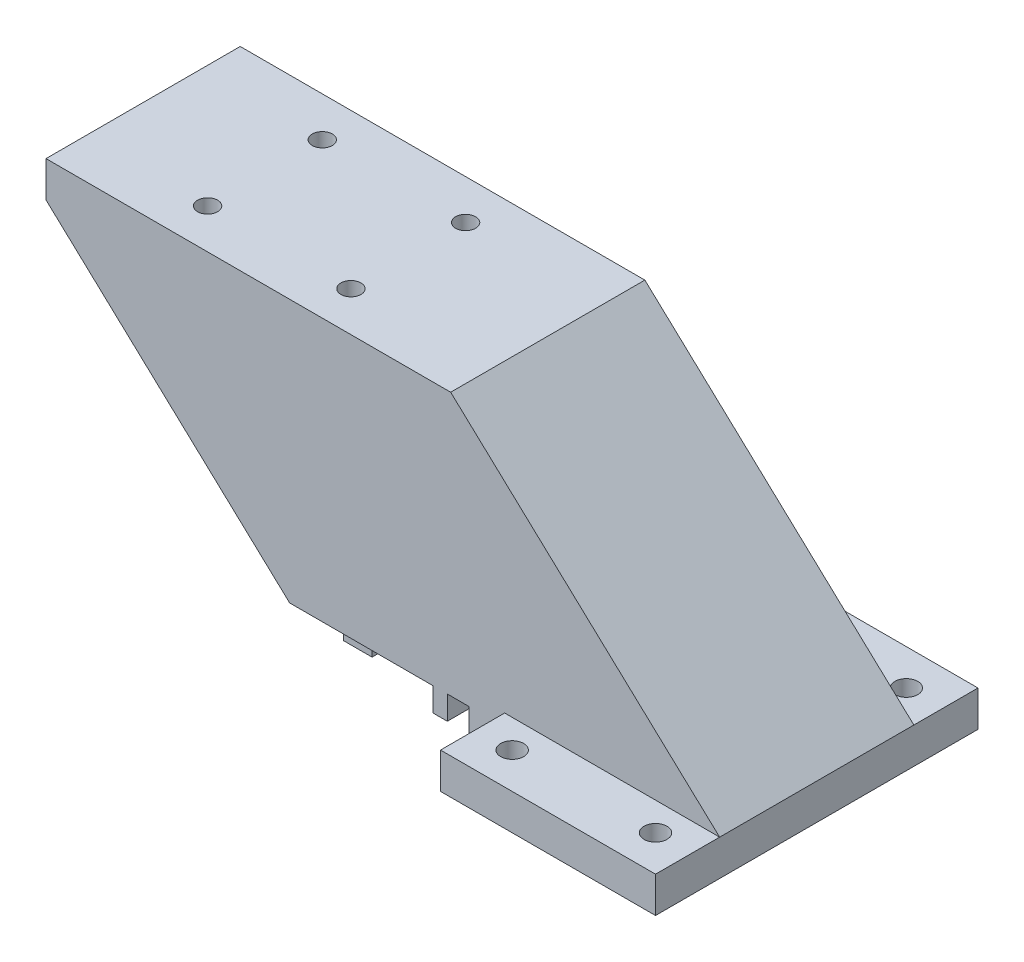
from build123d import *

# Parameters (mm, degrees)
SKETCH1_W                = 30
SKETCH1_H                = 45
SKETCH1_R                = 1.6
BOSS_EXTRUDE3_DEPTH      = 5
SKETCH2_W                = 64
SKETCH2_H                = 27.1
SKETCH2_W_2              = 30
BOSS_EXTRUDE4_DEPTH      = 35
BOSS_EXTRUDE4_DEPTH_BACK = 1.7
SKETCH3_W                = 4
SKETCH3_H                = 24.6
SKETCH3_W_2              = 5
SKETCH3_H_2              = 27.1
SKETCH3_W_3              = 2
BOSS_EXTRUDE5_DEPTH      = 3.3
SKETCH4_R                = 1.4
CUT_EXTRUDE1_DEPTH       = 41
CUT_EXTRUDE4_DEPTH       = 37.05
CUT_EXTRUDE5_DEPTH       = 10
CUT_EXTRUDE5_DEPTH_BACK  = 10
CUT_EXTRUDE6_DEPTH       = 37.05


with BuildPart() as part:
    # Sketch1 → Boss-Extrude3 (new body)
    with BuildSketch(Plane(origin=(0, 0, 0), x_dir=(1, 0, 0), z_dir=(0, 1, 0))):
        Rectangle(SKETCH1_W, SKETCH1_H)
        with Locations((-10, -17.5)):
            Circle(SKETCH1_R, mode=Mode.SUBTRACT)
        with Locations((10, -17.5)):
            Circle(SKETCH1_R, mode=Mode.SUBTRACT)
        with Locations((10, 17.5)):
            Circle(SKETCH1_R, mode=Mode.SUBTRACT)
        with Locations((-10, 17.5)):
            Circle(SKETCH1_R, mode=Mode.SUBTRACT)
        Polygon((-6, 22.5), (-15, 22.5), (-15, -22.5), (15, -22.5), (15, 22.5), (6, 22.5), align=None)
        with Locations((-10, -17.5)):
            Circle(SKETCH1_R, mode=Mode.SUBTRACT)
        with Locations((10, -17.5)):
            Circle(SKETCH1_R, mode=Mode.SUBTRACT)
        with Locations((-10, 17.5)):
            Circle(SKETCH1_R, mode=Mode.SUBTRACT)
        with Locations((10, 17.5)):
            Circle(SKETCH1_R, mode=Mode.SUBTRACT)
    extrude(amount=BOSS_EXTRUDE3_DEPTH)

    # Sketch2 → Boss-Extrude4 (add, two sides)
    with BuildSketch(Plane(origin=(0, 5, 0), x_dir=(1, 0, 0), z_dir=(0, 1, 0))) as boss_extrude4_sk:
        with Locations((-47, 0)):
            Rectangle(SKETCH2_W, SKETCH2_H)
        Rectangle(SKETCH2_W_2, SKETCH2_H)
    extrude(amount=BOSS_EXTRUDE4_DEPTH)
    extrude(boss_extrude4_sk.sketch, amount=-BOSS_EXTRUDE4_DEPTH_BACK)

    # Sketch3 → Boss-Extrude5 (add)
    with BuildSketch(Plane.XZ.offset(-3.3)):
        with Locations((-38, -1.25)):
            Rectangle(SKETCH3_W, SKETCH3_H)
        with Locations((-17.5, 0)):
            Rectangle(SKETCH3_W_2, SKETCH3_H_2)
        with Locations((-24, 0)):
            Rectangle(SKETCH3_W_3, SKETCH3_H_2)
    extrude(amount=BOSS_EXTRUDE5_DEPTH)

    # Sketch4 → Cut-Extrude1 (cut, through all)
    with BuildSketch(Plane(origin=(0, 40, 0), x_dir=(1, 0, 0), z_dir=(0, 1, 0))):
        with Locations((-62, 8)):
            Circle(SKETCH4_R)
        with Locations((-42, 8)):
            Circle(SKETCH4_R)
        with Locations((-42, -8)):
            Circle(SKETCH4_R)
        with Locations((-62, -8)):
            Circle(SKETCH4_R)
    extrude(amount=-CUT_EXTRUDE1_DEPTH, mode=Mode.SUBTRACT)

    # Sketch7 → Cut-Extrude4 (cut, through all)
    with BuildSketch(Plane.XY.offset(13.55)):
        Polygon((-45, 3.3), (-79, 35), (-79, 3.3), align=None)
    extrude(amount=-CUT_EXTRUDE4_DEPTH, mode=Mode.SUBTRACT)

    # Sketch8 → Cut-Extrude5 (cut, two sides)
    with BuildSketch(Plane(origin=(0, 0, 0), x_dir=(-1, 0, 0), z_dir=(0, 0, -1))) as cut_extrude5_sk:
        Polygon((79, 35), (34, 35), (34, 8.3), (40, 8.3), (40, 3.3), (51.306520611, 3.3), (51.306520611, 8.3), (79, 8.3), align=None)
    extrude(amount=CUT_EXTRUDE5_DEPTH, mode=Mode.SUBTRACT)
    extrude(cut_extrude5_sk.sketch, amount=-CUT_EXTRUDE5_DEPTH_BACK, mode=Mode.SUBTRACT)

    # Sketch9 → Cut-Extrude6 (cut, through all)
    with BuildSketch(Plane(origin=(0, 0, -13.55), x_dir=(-1, 0, 0), z_dir=(0, 0, -1))):
        Polygon((-15, 40), (-15, 5), (22.532904851, 40), align=None)
    extrude(amount=-CUT_EXTRUDE6_DEPTH, mode=Mode.SUBTRACT)


solid = part.part
